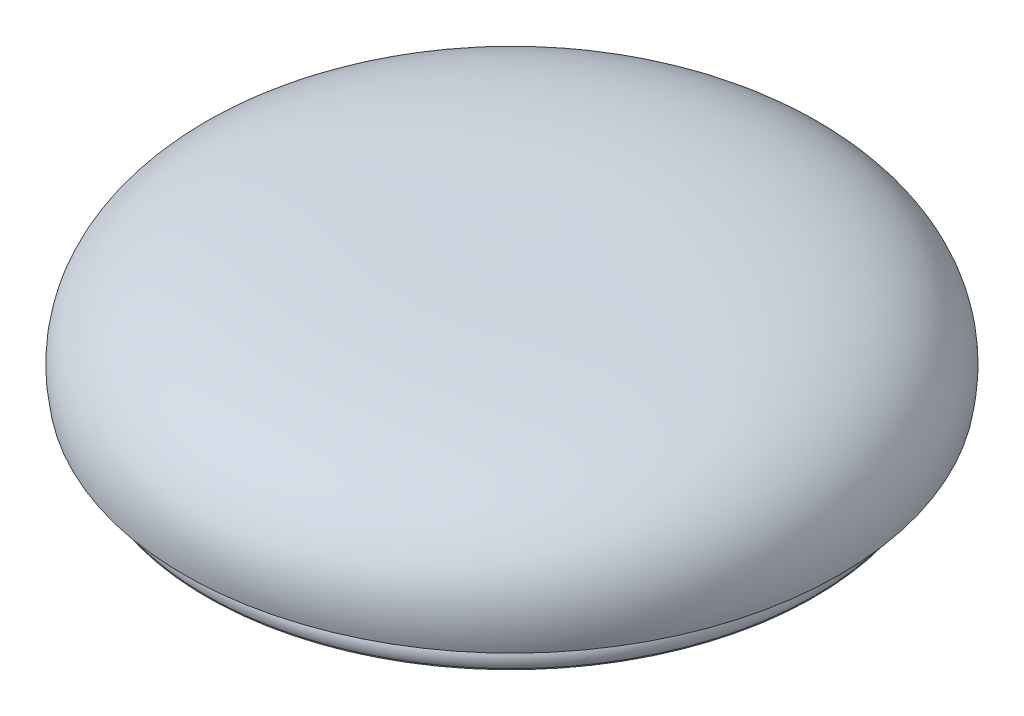
from build123d import *

# Parameters (mm, degrees)
SHELL1_T                         = -1
SKETCH11_R                       = 19
SKETCH11_R_2                     = 18
EXTRUDE_THIN13_DEPTH             = 2
EXTRUDE_THIN13_DIRECTION_2_REACH = 10.02
EXTRUDE_THIN14_REACH             = 8.611
SKETCH12_R                       = 18
SKETCH12_R_2                     = 17
BOSS_EXTRUDE10_DEPTH             = 2
SKETCH15_R                       = 19.878132793
SKETCH15_R_2                     = 18.878132793
EXTRUDE_THIN16_DEPTH             = 3.7


with BuildPart() as part:
    # Sketch1 → Revolve1 (revolve)
    with BuildSketch(Plane.XY):
        with BuildLine():
            Line((11.811389288, -9.261941751), (9.300113186, -9.261941751))
            Line((9.300113186, -9.261941751), (9.300113186, -9.958467397))
            Line((9.300113186, -9.958467397), (0.082702366, -9.958467397))
            Line((0.082702366, -9.958467397), (0.082702366, 4.562309175))
            add(Edge.make_bspline(
                [(16.601495938, -7.83707612), (17.235997857, -7.83707612), (19.914392759, -5.712739879), (21.575238992, -0.747313228), (17.669068824, 5.038679005), (2.394452084, 4.562309175), (0.082702366, 4.562309175)],
                knots=[0, 0, 0, 0, 0.060344305, 0.102248358, 0.311975325, 0.500299923, 0.500299923, 0.500299923, 0.500299923], degree=3))
            add(Edge.make_bspline(
                [(16.601495938, -7.83707612), (14.252483722, -8.708464841), (11.811389288, -9.261941751)],
                knots=[0, 0, 0, 1, 1, 1], degree=2))
        make_face()
    revolve(axis=Axis((0.082702366, -9.958467397, 0), (0, 1, 0)))


with BuildPart() as body_2:
    # Split1: the piece on the far side of the plane
    add(part.part)
    split(bisect_by=Plane.ZX.offset(-3.437690825), keep=Keep.BOTTOM)


with BuildPart() as part_1:
    add(part.part)

    # Split1
    split(bisect_by=Plane.ZX.offset(-3.437690825), keep=Keep.TOP)

    # Shell1
    shell1_openings = [part_1.faces().sort_by_distance(p)[0] for p in [
        (20.582702366, -3.437690825, 0),
    ]]
    offset(amount=SHELL1_T, openings=shell1_openings, kind=Kind.INTERSECTION)

    # Sketch11 → Extrude-Thin13 (add)
    with BuildSketch(Plane(origin=(0, -3.437690825, 0), x_dir=(-1, 0, 0), z_dir=(0, -1, 0))):
        Circle(SKETCH11_R)
        Circle(SKETCH11_R_2, mode=Mode.SUBTRACT)
    extrude(amount=EXTRUDE_THIN13_DEPTH)

    # Sketch11 → Extrude-Thin13 direction 2 (add, up to next)
    with BuildSketch(Plane(origin=(0, -3.437690825, 0), x_dir=(-1, 0, 0), z_dir=(0, -1, 0)), mode=Mode.PRIVATE) as extrude_thin13_direction_2_sk1:
        Circle(SKETCH11_R)
        Circle(SKETCH11_R_2, mode=Mode.SUBTRACT)
    extrude_thin13_direction_2_tool1 = extrude(extrude_thin13_direction_2_sk1.sketch, amount=-EXTRUDE_THIN13_DIRECTION_2_REACH, mode=Mode.PRIVATE) - part_1.part
    add(extrude_thin13_direction_2_tool1.solids().sort_by_distance((18.462599, -3.437691, 0))[0])

    # Sketch12 → Extrude-Thin14 (add, up to next)
    with BuildSketch(Plane(origin=(0, -1.737690825, 0), x_dir=(-1, 0, 0), z_dir=(0, -1, 0)), mode=Mode.PRIVATE) as extrude_thin14_sk1:
        Circle(SKETCH12_R)
        Circle(SKETCH12_R_2, mode=Mode.SUBTRACT)
    extrude_thin14_tool1 = extrude(extrude_thin14_sk1.sketch, amount=-EXTRUDE_THIN14_REACH, mode=Mode.PRIVATE) - part_1.part
    add(extrude_thin14_tool1.solids().sort_by_distance((17.490883, -1.737691, 0))[0])

    # Sketch13 → Boss-Extrude10 (add)
    with BuildSketch(Plane(origin=(0, -1.737690825, 0), x_dir=(-1, 0, 0), z_dir=(0, -1, 0))):
        with BuildLine():
            ThreePointArc((-17.972222222, 0.999614123), (-18, 0), (-17.972222222, -0.999614123))
            ThreePointArc((-17.972222222, -0.999614123), (-17, 0), (-17.972222222, 0.999614123))
        make_face()
        with BuildLine():
            ThreePointArc((-0.999614123, 17.972222222), (0, 17), (0.999614123, 17.972222222))
            ThreePointArc((0.999614123, 17.972222222), (0, 18), (-0.999614123, 17.972222222))
        make_face()
        with BuildLine():
            ThreePointArc((17.972222222, 0.999614123), (17, 0), (17.972222222, -0.999614123))
            ThreePointArc((17.972222222, -0.999614123), (18, 0), (17.972222222, 0.999614123))
        make_face()
        with BuildLine():
            ThreePointArc((0.999614123, -17.972222222), (0, -17), (-0.999614123, -17.972222222))
            ThreePointArc((-0.999614123, -17.972222222), (0, -18), (0.999614123, -17.972222222))
        make_face()
    extrude(amount=BOSS_EXTRUDE10_DEPTH)

    # Sketch14 → Revolve6 (revolve)
    with BuildSketch(Plane.XY):
        with BuildLine():
            Line((-18.968832742, -5.437690825), (-18.968832742, -4.433917221))
            ThreePointArc((-18.968832742, -4.433917221), (-19.103899428, -4.935804023), (-18.968832742, -5.437690825))
        make_face()
    revolve(axis=Axis((0, 0, 0), (0, -1, 0)))

    # Sketch15 → Extrude-Thin16 (add)
    with BuildSketch(Plane.XZ.offset(3.437690825)):
        with Locations((0.082702366, 0)):
            Circle(SKETCH15_R)
        with Locations((0.082702366, 0)):
            Circle(SKETCH15_R_2, mode=Mode.SUBTRACT)
    extrude(amount=-EXTRUDE_THIN16_DEPTH)


solid = part_1.part
